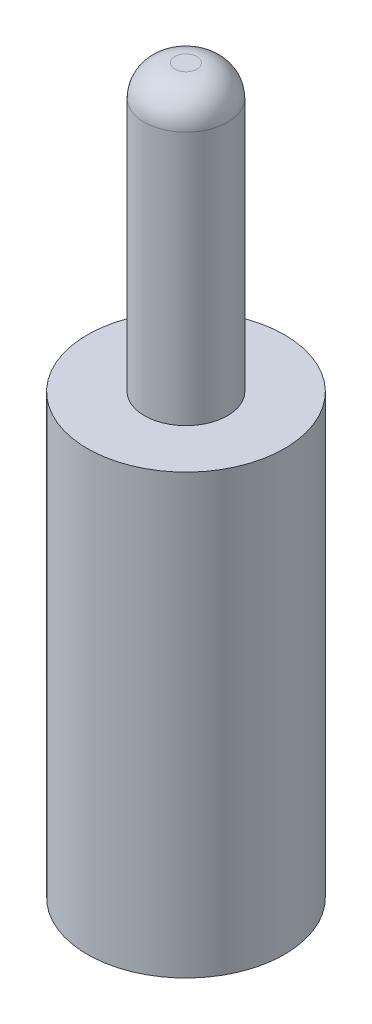
from build123d import *

# Parameters (mm, degrees)
SKETCH1_R           = 0.95
BOSS_EXTRUDE1_DEPTH = 6.5
SKETCH2_R           = 2.25
BOSS_EXTRUDE2_DEPTH = 10
FILLET1_R           = 0.7


with BuildPart() as part:
    # Sketch1 → Boss-Extrude1 (new body)
    with BuildSketch(Plane(origin=(0, 0, 0), x_dir=(1, 0, 0), z_dir=(0, 1, 0))):
        Circle(SKETCH1_R)
    extrude(amount=BOSS_EXTRUDE1_DEPTH)

    # Sketch2 → Boss-Extrude2 (add)
    with BuildSketch(Plane(origin=(0, 0, 0), x_dir=(-1, 0, 0), z_dir=(0, -1, 0))):
        Circle(SKETCH2_R)
    extrude(amount=BOSS_EXTRUDE2_DEPTH)

    # Fillet1
    fillet1_edges = [part.edges().sort_by_distance(p)[0] for p in [
        (-0.95, 6.5, 0),
    ]]
    fillet(fillet1_edges, radius=FILLET1_R)


solid = part.part
